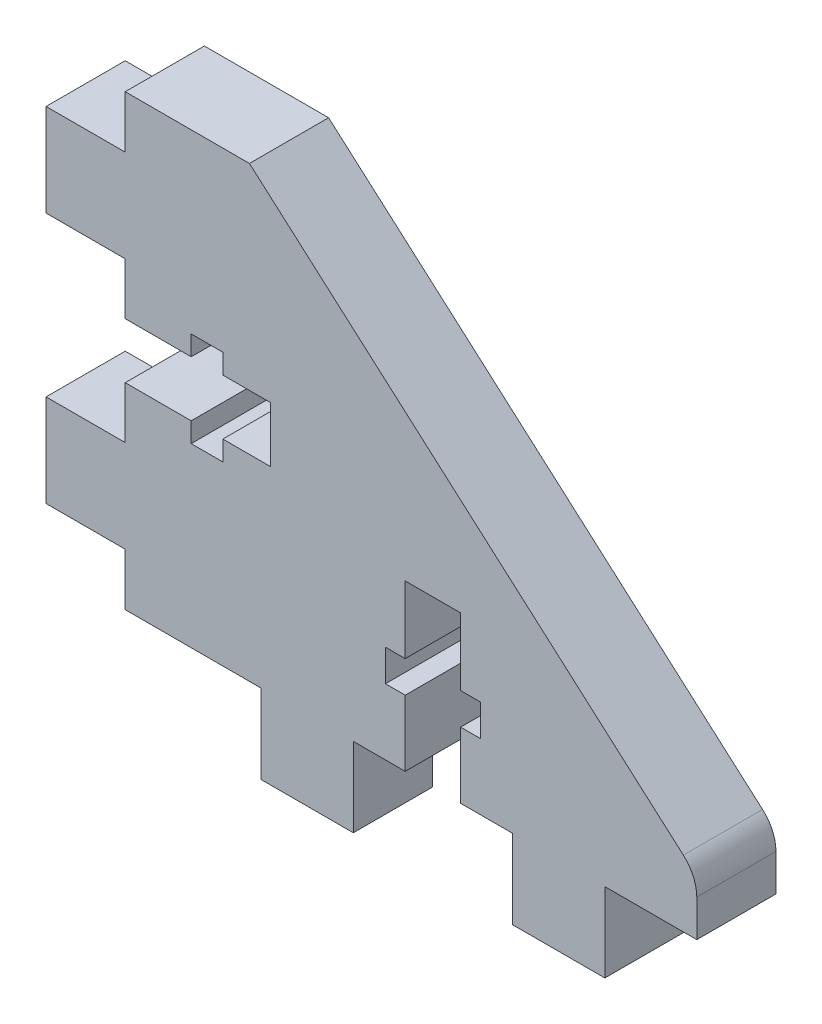
from build123d import *

# Parameters (mm, degrees)
EXTRUDE_1_DEPTH      = 6
SKETCH_2_W           = 7
SKETCH_2_H           = 6
EXTRUDE_2_DEPTH      = 6
CUT_EXTRUDE_1_DEPTH  = 7
SKETCH_21_W          = 7
SKETCH_21_H          = 6
EXTRUDE_21_DEPTH     = 6
SKETCH_22_W          = 7
SKETCH_22_H          = 6
EXTRUDE_22_DEPTH     = 6
CUT_EXTRUDE_12_DEPTH = 7
SKETCH_23_W          = 7
SKETCH_23_H          = 6
EXTRUDE_24_DEPTH     = 6


with BuildPart() as part:
    # Эскиз1 → Бобышка-Вытянуть1 (new body)
    with BuildSketch(Plane.XY):
        with BuildLine():
            Line((-44.810940225, 6.078379342), (-3.810940225, 6.078379342))
            Line((-3.810940225, 6.078379342), (-1.488167872, 6.078379342))
            Line((-1.488167872, 6.078379342), (-1.488167872, 8.8692773))
            ThreePointArc((-1.488167872, 8.8692773), (-1.754354552, 10.10469817), (-2.50567769, 11.120883988))
            Line((-2.50567769, 11.120883988), (-35.394057565, 40.078379342))
            Line((-35.394057565, 40.078379342), (-44.810940225, 40.078379342))
            Line((-44.810940225, 40.078379342), (-44.810940225, 6.078379342))
        make_face()
    extrude(amount=-EXTRUDE_1_DEPTH)

    # Эскиз2 → Бобышка-Вытянуть2 (add)
    with BuildSketch(Plane(origin=(5.189059775, 23.078379342, -6), x_dir=(0, -1, 0), z_dir=(0, 0, -1))):
        with Locations((-9.531849908, 53)):
            Rectangle(SKETCH_2_W, SKETCH_2_H)
        with Locations((9.531849908, 53)):
            Rectangle(SKETCH_2_W, SKETCH_2_H)
    extrude(amount=-EXTRUDE_2_DEPTH)

    # Эскиз3 → Вырез-Вытянуть1 (cut, through all)
    with BuildSketch(Plane(origin=(5.189059775, 23.078379342, -6), x_dir=(0, -1, 0), z_dir=(0, 0, -1))):
        Polygon((-2.1, 45), (-3.6, 45), (-3.6, 42.6), (-2.1, 42.6), (-2.1, 39), (2.1, 39), (2.1, 42.6), (3.6, 42.6), (3.6, 45), (2.1, 45), (2.1, 50), (-2.1, 50), align=None)
    extrude(amount=-CUT_EXTRUDE_1_DEPTH, mode=Mode.SUBTRACT)

    # Эскиз21 → Бобышка-Вытянуть21 (add)
    with BuildSketch(Plane(origin=(5.189059775, 23.078379342, 0), x_dir=(0, 1, 0), z_dir=(0, 0, 1))):
        with Locations((-9.531849908, 53)):
            Rectangle(SKETCH_21_W, SKETCH_21_H)
        with Locations((9.531849908, 53)):
            Rectangle(SKETCH_21_W, SKETCH_21_H)
    extrude(amount=-EXTRUDE_21_DEPTH)

    # Эскиз22 → Бобышка-Вытянуть22 (add)
    with BuildSketch(Plane(origin=(-21.488167872, 56.078379342, 0), x_dir=(-1, 0, 0), z_dir=(0, 0, 1))):
        with Locations((-9.531849908, 53)):
            Rectangle(SKETCH_22_W, SKETCH_22_H)
        with Locations((9.531849908, 53)):
            Rectangle(SKETCH_22_W, SKETCH_22_H)
    extrude(amount=-EXTRUDE_22_DEPTH)

    # Эскиз32 → Вырез-Вытянуть12 (cut, through all)
    with BuildSketch(Plane(origin=(-21.488167872, 56.078379342, 0), x_dir=(-1, 0, 0), z_dir=(0, 0, 1))):
        Polygon((-2.1, 45), (-3.6, 45), (-3.6, 42.6), (-2.1, 42.6), (-2.1, 37.5), (2.1, 37.5), (2.1, 42.6), (3.6, 42.6), (3.6, 45), (2.1, 45), (2.1, 50), (-2.1, 50), align=None)
    extrude(amount=-CUT_EXTRUDE_12_DEPTH, mode=Mode.SUBTRACT)

    # Эскиз23 → Бобышка-Вытянуть24 (add)
    with BuildSketch(Plane(origin=(-21.488167872, 56.078379342, -6), x_dir=(1, 0, 0), z_dir=(0, 0, -1))):
        with Locations((-9.531849908, 53)):
            Rectangle(SKETCH_23_W, SKETCH_23_H)
        with Locations((9.531849908, 53)):
            Rectangle(SKETCH_23_W, SKETCH_23_H)
    extrude(amount=-EXTRUDE_24_DEPTH)


solid = part.part
